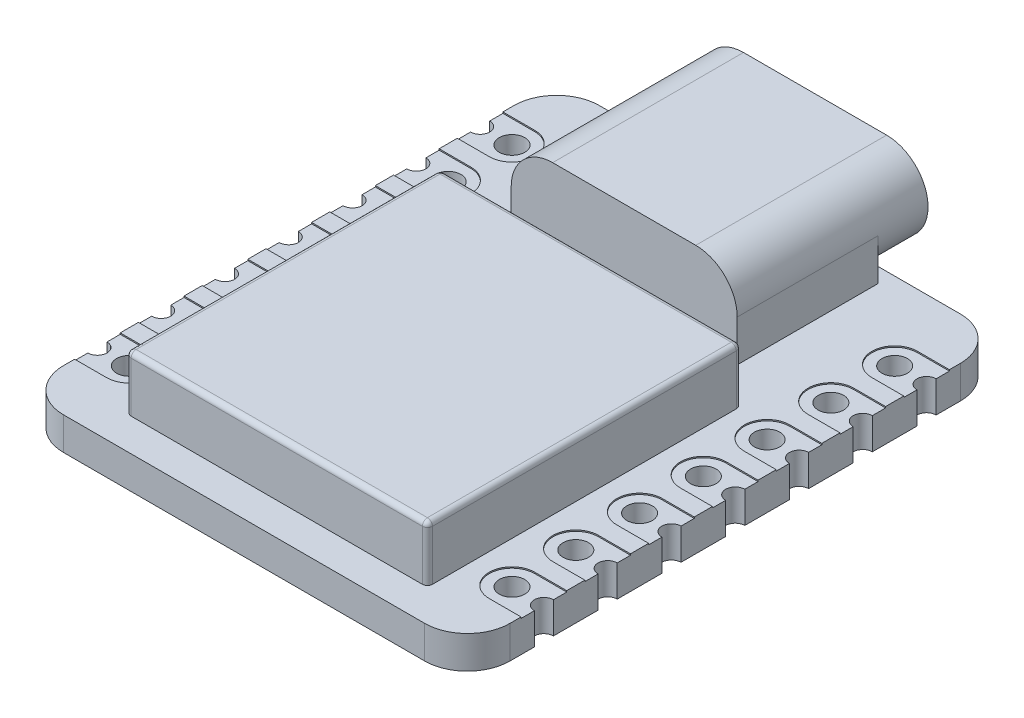
from build123d import *

# Parameters (mm, degrees)
SKETCH1_W                 = 17.78
SKETCH1_H                 = 21.336
BOSS_EXTRUDE1_DEPTH       = 1.3
SKETCH2_W                 = 12
SKETCH2_H                 = 12.5
BOSS_EXTRUDE2_DEPTH       = 2.2
SKETCH4_W                 = 9
SKETCH4_H                 = 7.6
BOSS_EXTRUDE3_DEPTH       = 3.3
CUT_EXTRUDE1_DEPTH        = 2
CUT_EXTRUDE2_DEPTH        = 7.6
FILLET1_R                 = 0.2
FILLET2_R                 = 1.7
SKETCH6_R                 = 0.508
SKETCH6_R_2               = 0.381
CUT_EXTRUDE3_DEPTH        = 2.3
CUT_EXTRUDE4_DEPTH        = 0.05
LPATTERN1_COUNT           = 7
LPATTERN1_PITCH           = 2.54
MIRROR1_COPY_1_SKETCH_R   = 0.508
MIRROR1_COPY_1_SKETCH_R_2 = 0.381
MIRROR1_COPY_1_DEPTH      = 2.3
MIRROR1_COPY_2_SKETCH_R   = 0.508
MIRROR1_COPY_2_SKETCH_R_2 = 0.381
MIRROR1_COPY_2_DEPTH      = 2.3
MIRROR1_COPY_3_SKETCH_R   = 0.508
MIRROR1_COPY_3_SKETCH_R_2 = 0.381
MIRROR1_COPY_3_DEPTH      = 2.3
MIRROR1_COPY_4_SKETCH_R   = 0.508
MIRROR1_COPY_4_SKETCH_R_2 = 0.381
MIRROR1_COPY_4_DEPTH      = 2.3
MIRROR1_COPY_5_SKETCH_R   = 0.508
MIRROR1_COPY_5_SKETCH_R_2 = 0.381
MIRROR1_COPY_5_DEPTH      = 2.3
MIRROR1_COPY_6_SKETCH_R   = 0.508
MIRROR1_COPY_6_SKETCH_R_2 = 0.381
MIRROR1_COPY_6_DEPTH      = 2.3
MIRROR1_COPY_7_DEPTH      = 0.05
MIRROR1_COPY_8_DEPTH      = 0.05
MIRROR1_COPY_9_DEPTH      = 0.05
MIRROR1_COPY_10_DEPTH     = 0.05
MIRROR1_COPY_11_DEPTH     = 0.05
MIRROR1_COPY_12_DEPTH     = 0.05
CUT_EXTRUDE5_DEPTH        = 5


with BuildPart() as part:
    # Sketch1 → Boss-Extrude1 (new body)
    with BuildSketch(Plane(origin=(0, 0, 0), x_dir=(1, 0, 0), z_dir=(0, 1, 0))):
        Rectangle(SKETCH1_W, SKETCH1_H)
    extrude(amount=BOSS_EXTRUDE1_DEPTH)

    # Sketch2 → Boss-Extrude2 (add)
    with BuildSketch(Plane(origin=(0, 1.3, 0), x_dir=(1, 0, 0), z_dir=(0, 1, 0))):
        with Locations((0, -3.118)):
            Rectangle(SKETCH2_W, SKETCH2_H)
    extrude(amount=BOSS_EXTRUDE2_DEPTH)

    # Sketch4 → Boss-Extrude3 (add)
    with BuildSketch(Plane(origin=(0, 1.3, 0), x_dir=(1, 0, 0), z_dir=(0, 1, 0))):
        with Locations((0, 8.268)):
            Rectangle(SKETCH4_W, SKETCH4_H)
    extrude(amount=BOSS_EXTRUDE3_DEPTH)

    # Sketch5 → Cut-Extrude1 (cut)
    with BuildSketch(Plane(origin=(0, 0, -12.068), x_dir=(-1, 0, 0), z_dir=(0, 0, -1))):
        with BuildLine():
            ThreePointArc((-2.85, 1.3), (-4.016726189, 1.783273811), (-4.5, 2.95))
            Line((-4.5, 2.95), (-4.5, 1.3))
            Line((-4.5, 1.3), (-2.85, 1.3))
        make_face()
        with BuildLine():
            Line((4.5, 1.3), (4.5, 2.95))
            ThreePointArc((4.5, 2.95), (4.016726189, 1.783273811), (2.85, 1.3))
            Line((2.85, 1.3), (4.5, 1.3))
        make_face()
    extrude(amount=-CUT_EXTRUDE1_DEPTH, mode=Mode.SUBTRACT)

    # Sketch5_3 → Cut-Extrude2 (cut)
    with BuildSketch(Plane(origin=(0, 0, -12.068), x_dir=(-1, 0, 0), z_dir=(0, 0, -1))):
        with BuildLine():
            Line((4.5, 4.6), (2.85, 4.6))
            ThreePointArc((2.85, 4.6), (4.016726189, 4.116726189), (4.5, 2.95))
            Line((4.5, 2.95), (4.5, 4.6))
        make_face()
        with BuildLine():
            ThreePointArc((-4.5, 2.95), (-4.016726189, 4.116726189), (-2.85, 4.6))
            Line((-2.85, 4.6), (-4.5, 4.6))
            Line((-4.5, 4.6), (-4.5, 2.95))
        make_face()
    extrude(amount=-CUT_EXTRUDE2_DEPTH, mode=Mode.SUBTRACT)

    # Fillet1
    fillet1_edges = [part.edges().sort_by_distance(p)[0] for p in [
        (6, 2.4, 9.368),
        (6, 2.4, -3.132),
        (-6, 2.4, -3.132),
        (-6, 2.4, 9.368),
        (6, 3.5, 3.118),
        (0, 3.5, -3.132),
        (-6, 3.5, 3.118),
        (0, 3.5, 9.368),
    ]]
    fillet(fillet1_edges, radius=FILLET1_R)

    # Fillet2
    fillet2_edges = [part.edges().sort_by_distance(p)[0] for p in [
        (-8.89, 0.65, -10.668),
        (8.89, 0.65, -10.668),
        (8.89, 0.65, 10.668),
        (-8.89, 0.65, 10.668),
    ]]
    fillet(fillet2_edges, radius=FILLET2_R)

    # Sketch6 → Cut-Extrude3 (cut, through all)
    with BuildSketch(Plane(origin=(0, 1.3, 0), x_dir=(1, 0, 0), z_dir=(0, 1, 0))):
        with Locations((-7.62, 7.62)):
            Circle(SKETCH6_R)
        with Locations((-8.89, 7.62)):
            Circle(SKETCH6_R_2)
    cut_extrude3 = extrude(amount=-CUT_EXTRUDE3_DEPTH, mode=Mode.SUBTRACT)

    # Sketch7 → Cut-Extrude4 (cut)
    with BuildSketch(Plane(origin=(0, 1.3, 0), x_dir=(1, 0, 0), z_dir=(0, 1, 0))):
        with BuildLine():
            Line((-8.89, 8.528), (-7.62, 8.528))
            ThreePointArc((-7.62, 8.528), (-6.712, 7.62), (-7.62, 6.712))
            Line((-7.62, 6.712), (-8.89, 6.712))
            Line((-8.89, 6.712), (-8.89, 8.528))
        make_face()
    cut_extrude4 = extrude(amount=-CUT_EXTRUDE4_DEPTH, mode=Mode.SUBTRACT)

    # LPattern1: Cut-Extrude3, Cut-Extrude4 ×7
    with Locations(*[(0, 0, i * LPATTERN1_PITCH) for i in range(1, LPATTERN1_COUNT)]):
        add(cut_extrude3, mode=Mode.SUBTRACT)
        add(cut_extrude4, mode=Mode.SUBTRACT)

    # Mirror1: Cut-Extrude3, Cut-Extrude4 across plane
    add(cut_extrude3.mirror(Plane(origin=(0, 0, 0), x_dir=(0, 0, 1), z_dir=(1, 0, 0))), mode=Mode.SUBTRACT)
    add(cut_extrude4.mirror(Plane(origin=(0, 0, 0), x_dir=(0, 0, 1), z_dir=(1, 0, 0))), mode=Mode.SUBTRACT)

    # Mirror1 copy 1 sketch → Mirror1 copy 1 (cut, through all)
    with BuildSketch(Plane(origin=(0, 1.3, 2.54), x_dir=(-1, 0, 0), z_dir=(0, 1, 0))):
        with Locations((-7.62, -7.62)):
            Circle(MIRROR1_COPY_1_SKETCH_R)
        with Locations((-8.89, -7.62)):
            Circle(MIRROR1_COPY_1_SKETCH_R_2)
    extrude(amount=-MIRROR1_COPY_1_DEPTH, mode=Mode.SUBTRACT)

    # Mirror1 copy 2 sketch → Mirror1 copy 2 (cut, through all)
    with BuildSketch(Plane(origin=(0, 1.3, 5.08), x_dir=(-1, 0, 0), z_dir=(0, 1, 0))):
        with Locations((-7.62, -7.62)):
            Circle(MIRROR1_COPY_2_SKETCH_R)
        with Locations((-8.89, -7.62)):
            Circle(MIRROR1_COPY_2_SKETCH_R_2)
    extrude(amount=-MIRROR1_COPY_2_DEPTH, mode=Mode.SUBTRACT)

    # Mirror1 copy 3 sketch → Mirror1 copy 3 (cut, through all)
    with BuildSketch(Plane(origin=(0, 1.3, 7.62), x_dir=(-1, 0, 0), z_dir=(0, 1, 0))):
        with Locations((-7.62, -7.62)):
            Circle(MIRROR1_COPY_3_SKETCH_R)
        with Locations((-8.89, -7.62)):
            Circle(MIRROR1_COPY_3_SKETCH_R_2)
    extrude(amount=-MIRROR1_COPY_3_DEPTH, mode=Mode.SUBTRACT)

    # Mirror1 copy 4 sketch → Mirror1 copy 4 (cut, through all)
    with BuildSketch(Plane(origin=(0, 1.3, 10.16), x_dir=(-1, 0, 0), z_dir=(0, 1, 0))):
        with Locations((-7.62, -7.62)):
            Circle(MIRROR1_COPY_4_SKETCH_R)
        with Locations((-8.89, -7.62)):
            Circle(MIRROR1_COPY_4_SKETCH_R_2)
    extrude(amount=-MIRROR1_COPY_4_DEPTH, mode=Mode.SUBTRACT)

    # Mirror1 copy 5 sketch → Mirror1 copy 5 (cut, through all)
    with BuildSketch(Plane(origin=(0, 1.3, 12.7), x_dir=(-1, 0, 0), z_dir=(0, 1, 0))):
        with Locations((-7.62, -7.62)):
            Circle(MIRROR1_COPY_5_SKETCH_R)
        with Locations((-8.89, -7.62)):
            Circle(MIRROR1_COPY_5_SKETCH_R_2)
    extrude(amount=-MIRROR1_COPY_5_DEPTH, mode=Mode.SUBTRACT)

    # Mirror1 copy 6 sketch → Mirror1 copy 6 (cut, through all)
    with BuildSketch(Plane(origin=(0, 1.3, 15.24), x_dir=(-1, 0, 0), z_dir=(0, 1, 0))):
        with Locations((-7.62, -7.62)):
            Circle(MIRROR1_COPY_6_SKETCH_R)
        with Locations((-8.89, -7.62)):
            Circle(MIRROR1_COPY_6_SKETCH_R_2)
    extrude(amount=-MIRROR1_COPY_6_DEPTH, mode=Mode.SUBTRACT)

    # Mirror1 copy 7 sketch → Mirror1 copy 7 (cut)
    with BuildSketch(Plane(origin=(0, 1.3, 2.54), x_dir=(-1, 0, 0), z_dir=(0, 1, 0))):
        with BuildLine():
            Line((-8.89, -8.528), (-7.62, -8.528))
            ThreePointArc((-7.62, -8.528), (-6.712, -7.62), (-7.62, -6.712))
            Line((-7.62, -6.712), (-8.89, -6.712))
            Line((-8.89, -6.712), (-8.89, -8.528))
        make_face()
    extrude(amount=-MIRROR1_COPY_7_DEPTH, mode=Mode.SUBTRACT)

    # Mirror1 copy 8 sketch → Mirror1 copy 8 (cut)
    with BuildSketch(Plane(origin=(0, 1.3, 5.08), x_dir=(-1, 0, 0), z_dir=(0, 1, 0))):
        with BuildLine():
            Line((-8.89, -8.528), (-7.62, -8.528))
            ThreePointArc((-7.62, -8.528), (-6.712, -7.62), (-7.62, -6.712))
            Line((-7.62, -6.712), (-8.89, -6.712))
            Line((-8.89, -6.712), (-8.89, -8.528))
        make_face()
    extrude(amount=-MIRROR1_COPY_8_DEPTH, mode=Mode.SUBTRACT)

    # Mirror1 copy 9 sketch → Mirror1 copy 9 (cut)
    with BuildSketch(Plane(origin=(0, 1.3, 7.62), x_dir=(-1, 0, 0), z_dir=(0, 1, 0))):
        with BuildLine():
            Line((-8.89, -8.528), (-7.62, -8.528))
            ThreePointArc((-7.62, -8.528), (-6.712, -7.62), (-7.62, -6.712))
            Line((-7.62, -6.712), (-8.89, -6.712))
            Line((-8.89, -6.712), (-8.89, -8.528))
        make_face()
    extrude(amount=-MIRROR1_COPY_9_DEPTH, mode=Mode.SUBTRACT)

    # Mirror1 copy 10 sketch → Mirror1 copy 10 (cut)
    with BuildSketch(Plane(origin=(0, 1.3, 10.16), x_dir=(-1, 0, 0), z_dir=(0, 1, 0))):
        with BuildLine():
            Line((-8.89, -8.528), (-7.62, -8.528))
            ThreePointArc((-7.62, -8.528), (-6.712, -7.62), (-7.62, -6.712))
            Line((-7.62, -6.712), (-8.89, -6.712))
            Line((-8.89, -6.712), (-8.89, -8.528))
        make_face()
    extrude(amount=-MIRROR1_COPY_10_DEPTH, mode=Mode.SUBTRACT)

    # Mirror1 copy 11 sketch → Mirror1 copy 11 (cut)
    with BuildSketch(Plane(origin=(0, 1.3, 12.7), x_dir=(-1, 0, 0), z_dir=(0, 1, 0))):
        with BuildLine():
            Line((-8.89, -8.528), (-7.62, -8.528))
            ThreePointArc((-7.62, -8.528), (-6.712, -7.62), (-7.62, -6.712))
            Line((-7.62, -6.712), (-8.89, -6.712))
            Line((-8.89, -6.712), (-8.89, -8.528))
        make_face()
    extrude(amount=-MIRROR1_COPY_11_DEPTH, mode=Mode.SUBTRACT)

    # Mirror1 copy 12 sketch → Mirror1 copy 12 (cut)
    with BuildSketch(Plane(origin=(0, 1.3, 15.24), x_dir=(-1, 0, 0), z_dir=(0, 1, 0))):
        with BuildLine():
            Line((-8.89, -8.528), (-7.62, -8.528))
            ThreePointArc((-7.62, -8.528), (-6.712, -7.62), (-7.62, -6.712))
            Line((-7.62, -6.712), (-8.89, -6.712))
            Line((-8.89, -6.712), (-8.89, -8.528))
        make_face()
    extrude(amount=-MIRROR1_COPY_12_DEPTH, mode=Mode.SUBTRACT)

    # Sketch8 → Cut-Extrude5 (cut)
    with BuildSketch(Plane(origin=(0, 0, -12.068), x_dir=(-1, 0, 0), z_dir=(0, 0, -1))):
        with BuildLine():
            Line((2.85, 4.4), (-2.85, 4.4))
            ThreePointArc((-2.85, 4.4), (-4.3, 2.95), (-2.85, 1.5))
            Line((-2.85, 1.5), (2.85, 1.5))
            ThreePointArc((2.85, 1.5), (4.3, 2.95), (2.85, 4.4))
        make_face()
    extrude(amount=-CUT_EXTRUDE5_DEPTH, mode=Mode.SUBTRACT)


solid = part.part
